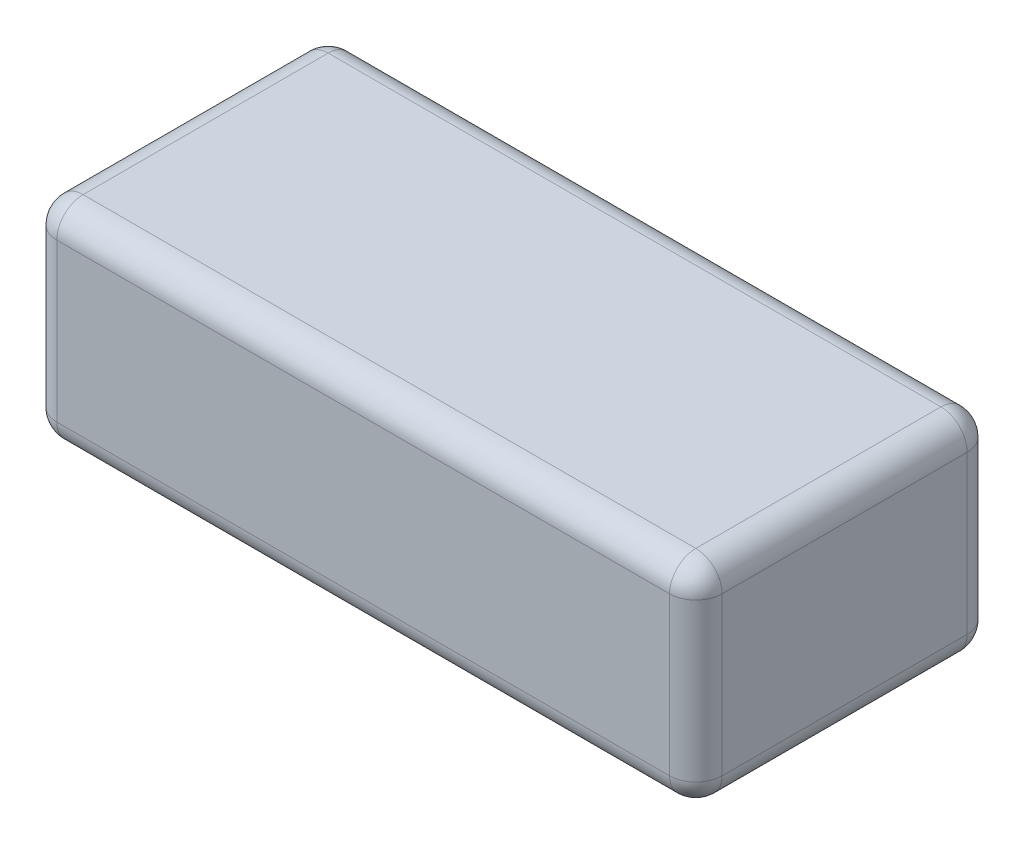
from build123d import *

# Parameters (mm, degrees)
SKETCH1_W           = 34
SKETCH1_H           = 24
BOSS_EXTRUDE1_DEPTH = 76
FILLET1_R           = 3


with BuildPart() as part:
    # Sketch1 → Boss-Extrude1 (new body)
    with BuildSketch(Plane(origin=(0, 0, 0), x_dir=(0, 0, -1), z_dir=(1, 0, 0))):
        with Locations((-17, 12)):
            Rectangle(SKETCH1_W, SKETCH1_H)
    extrude(amount=-BOSS_EXTRUDE1_DEPTH)

    # Fillet1
    fillet1_edges = [part.edges().sort_by_distance(p)[0] for p in [
        (-76, 12, 34),
        (-76, 0, 17),
        (-76, 12, 0),
        (0, 0, 17),
        (0, 12, 34),
        (0, 24, 17),
        (0, 12, 0),
        (-38, 0, 0),
        (-38, 0, 34),
        (-38, 24, 34),
        (-38, 24, 0),
        (-76, 24, 17),
    ]]
    fillet(fillet1_edges, radius=FILLET1_R)


solid = part.part
